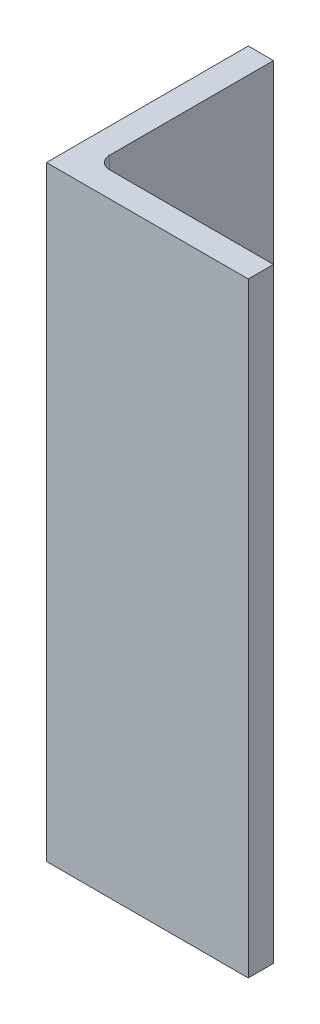
from build123d import *

# Parameters (mm, degrees)
BOSS_EXTRUDE1_DEPTH             = 152.4
FILLET1_R                       = 3.175
F_3_4_0_75_DIAMETER_HOLE1_D     = 19.05
F_3_4_0_75_DIAMETER_HOLE1_DEPTH = 6.35


with BuildPart() as part:
    # Sketch1 → Boss-Extrude1 (new body)
    with BuildSketch(Plane(origin=(0, 0, 0), x_dir=(1, 0, 0), z_dir=(0, 1, 0))):
        Polygon((0, 0), (0, 50.8), (6.35, 50.8), (6.35, 6.35), (50.8, 6.35), (50.8, 0), align=None)
    extrude(amount=BOSS_EXTRUDE1_DEPTH)

    # Fillet1
    fillet1_edges = [part.edges().sort_by_distance(p)[0] for p in [
        (6.35, 76.2, -6.35),
    ]]
    fillet(fillet1_edges, radius=FILLET1_R)

    # 3/4 (0.75) Diameter Hole1
    with Locations(Plane.ZY):
        with Locations((-25.4, 31.75)):
            Hole(F_3_4_0_75_DIAMETER_HOLE1_D / 2, depth=F_3_4_0_75_DIAMETER_HOLE1_DEPTH)


solid = part.part
